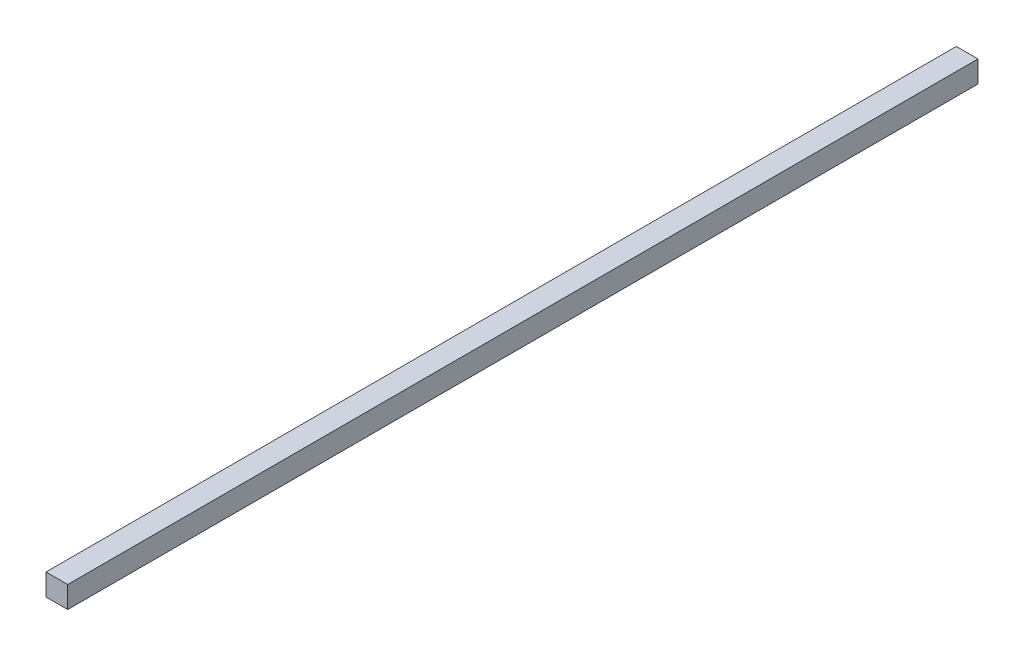
from build123d import *

# Parameters (mm, degrees)
SKETCH1_W           = 25.4
SKETCH1_H           = 1066.497576181
BOSS_EXTRUDE1_DEPTH = 25.4


with BuildPart() as part:
    # Sketch1 → Boss-Extrude1 (new body)
    with BuildSketch(Plane(origin=(0, 0, 0), x_dir=(1, 0, 0), z_dir=(0, 1, 0))):
        with Locations((12.7, 533.248788091)):
            Rectangle(SKETCH1_W, SKETCH1_H)
    extrude(amount=BOSS_EXTRUDE1_DEPTH)


solid = part.part
